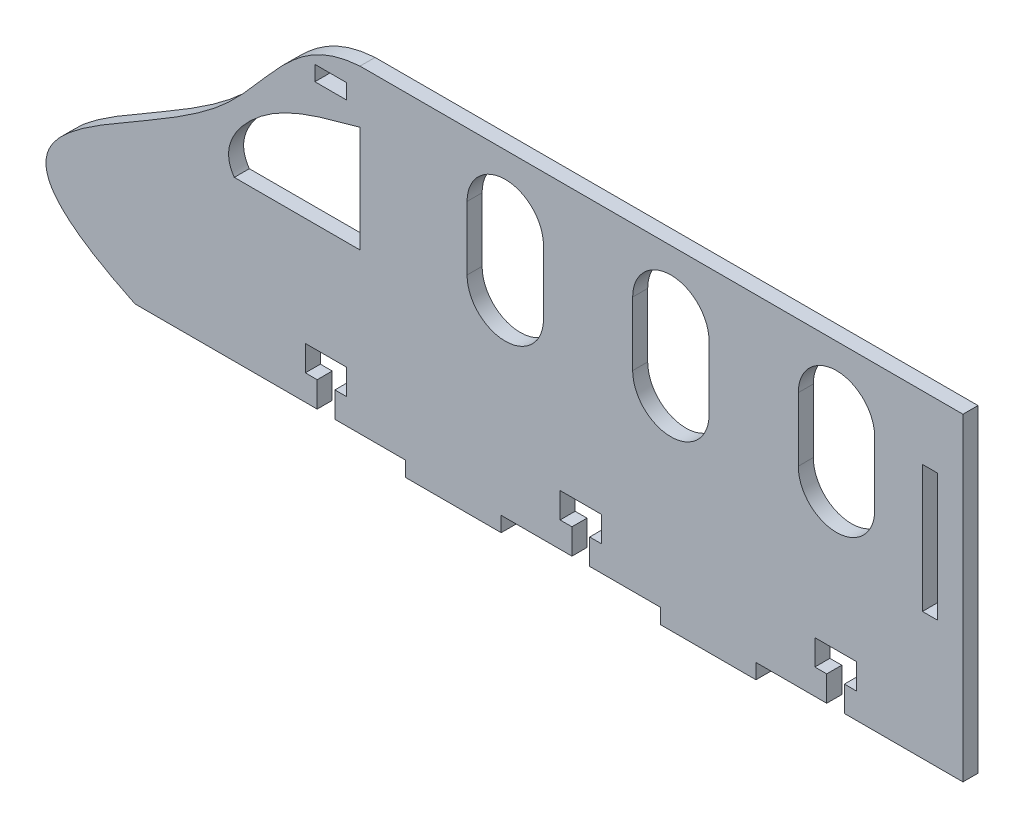
from build123d import *

# Parameters (mm, degrees)
SKETCH1_W           = 3
SKETCH1_H           = 25.4
SKETCH1_W_2         = 6.35
SKETCH1_H_2         = 3
BOSS_EXTRUDE1_DEPTH = 3


with BuildPart() as part:
    # Sketch1 → Boss-Extrude1 (new body)
    with BuildSketch(Plane.XY):
        with BuildLine():
            Line((-69.423123959, 31.75), (50.8, 31.75))
            Line((50.8, 31.75), (50.8, -31.75))
            Line((50.8, -31.75), (27.1653, -31.75))
            Line((27.1653, -31.75), (27.1653, -26.67))
            Line((27.1653, -26.67), (29.5275, -26.67))
            Line((29.5275, -26.67), (29.5275, -21.59))
            Line((29.5275, -21.59), (21.2725, -21.59))
            Line((21.2725, -21.59), (21.2725, -26.67))
            Line((21.2725, -26.67), (23.6347, -26.67))
            Line((23.6347, -26.67), (23.6347, -31.75))
            Line((23.6347, -31.75), (9.525, -31.75))
            Line((9.525, -31.75), (9.525, -34.75))
            Line((9.525, -34.75), (-9.525, -34.75))
            Line((-9.525, -34.75), (-9.525, -31.75))
            Line((-9.525, -31.75), (-23.6347, -31.75))
            Line((-23.6347, -31.75), (-23.6347, -26.67))
            Line((-23.6347, -26.67), (-21.2725, -26.67))
            Line((-21.2725, -26.67), (-21.2725, -21.59))
            Line((-21.2725, -21.59), (-29.5275, -21.59))
            Line((-29.5275, -21.59), (-29.5275, -26.67))
            Line((-29.5275, -26.67), (-27.1653, -26.67))
            Line((-27.1653, -26.67), (-27.1653, -31.75))
            Line((-27.1653, -31.75), (-41.275, -31.75))
            Line((-41.275, -31.75), (-41.275, -34.75))
            Line((-41.275, -34.75), (-60.325, -34.75))
            Line((-60.325, -34.75), (-60.325, -31.75))
            Line((-60.325, -31.75), (-74.4347, -31.75))
            Line((-74.4347, -31.75), (-74.4347, -26.67))
            Line((-74.4347, -26.67), (-72.0725, -26.67))
            Line((-72.0725, -26.67), (-72.0725, -21.59))
            Line((-72.0725, -21.59), (-80.3275, -21.59))
            Line((-80.3275, -21.59), (-80.3275, -26.67))
            Line((-80.3275, -26.67), (-77.9653, -26.67))
            Line((-77.9653, -26.67), (-77.9653, -31.75))
            Line((-77.9653, -31.75), (-114.3, -31.75))
            add(Edge.make_bspline(
                [(-114.3, -31.75), (-155.075216818, -12.249007941), (-95.203771035, -1.48614813), (-82.940088204, 30.901814597), (-69.423123959, 31.75)],
                knots=[0, 0, 0, 0, 0.663381838, 1, 1, 1, 1], degree=3))
        make_face()
        with BuildLine():
            Line((33.200035124, 19.05), (33.200035124, 6.35))
            ThreePointArc((33.200035124, 6.35), (25.580035124, -1.27), (17.960035124, 6.35))
            Line((17.960035124, 6.35), (17.960035124, 19.05))
            ThreePointArc((17.960035124, 19.05), (25.580035124, 26.67), (33.200035124, 19.05))
        make_face(mode=Mode.SUBTRACT)
        with BuildLine():
            Line((-69.423123959, 0), (-69.423123959, 21.185554356))
            add(Edge.make_bspline(
                [(-69.423123959, 21.185554356), (-77.065116074, 19.019259029), (-89.179513015, 16.560411812), (-97.292708494, 3.952124557), (-94.492767951, 0)],
                knots=[0, 0, 0, 0, 0.649291819, 1, 1, 1, 1], degree=3))
            Line((-94.492767951, 0), (-69.423123959, 0))
        make_face(mode=Mode.SUBTRACT)
        with BuildLine():
            Line((0.180035124, 19.05), (0.180035124, 6.35))
            ThreePointArc((0.180035124, 6.35), (-7.439964876, -1.27), (-15.059964876, 6.35))
            Line((-15.059964876, 6.35), (-15.059964876, 19.05))
            ThreePointArc((-15.059964876, 19.05), (-7.439964876, 26.67), (0.180035124, 19.05))
        make_face(mode=Mode.SUBTRACT)
        with BuildLine():
            Line((-32.839964876, 19.05), (-32.839964876, 6.35))
            ThreePointArc((-32.839964876, 6.35), (-40.459964876, -1.27), (-48.079964876, 6.35))
            Line((-48.079964876, 6.35), (-48.079964876, 19.05))
            ThreePointArc((-48.079964876, 19.05), (-40.459964876, 26.67), (-32.839964876, 19.05))
        make_face(mode=Mode.SUBTRACT)
        with Locations((44.22, 6.35)):
            Rectangle(SKETCH1_W, SKETCH1_H, mode=Mode.SUBTRACT)
        with Locations((-75.2475, 26.052973764)):
            Rectangle(SKETCH1_W_2, SKETCH1_H_2, mode=Mode.SUBTRACT)
    extrude(amount=BOSS_EXTRUDE1_DEPTH)


solid = part.part
